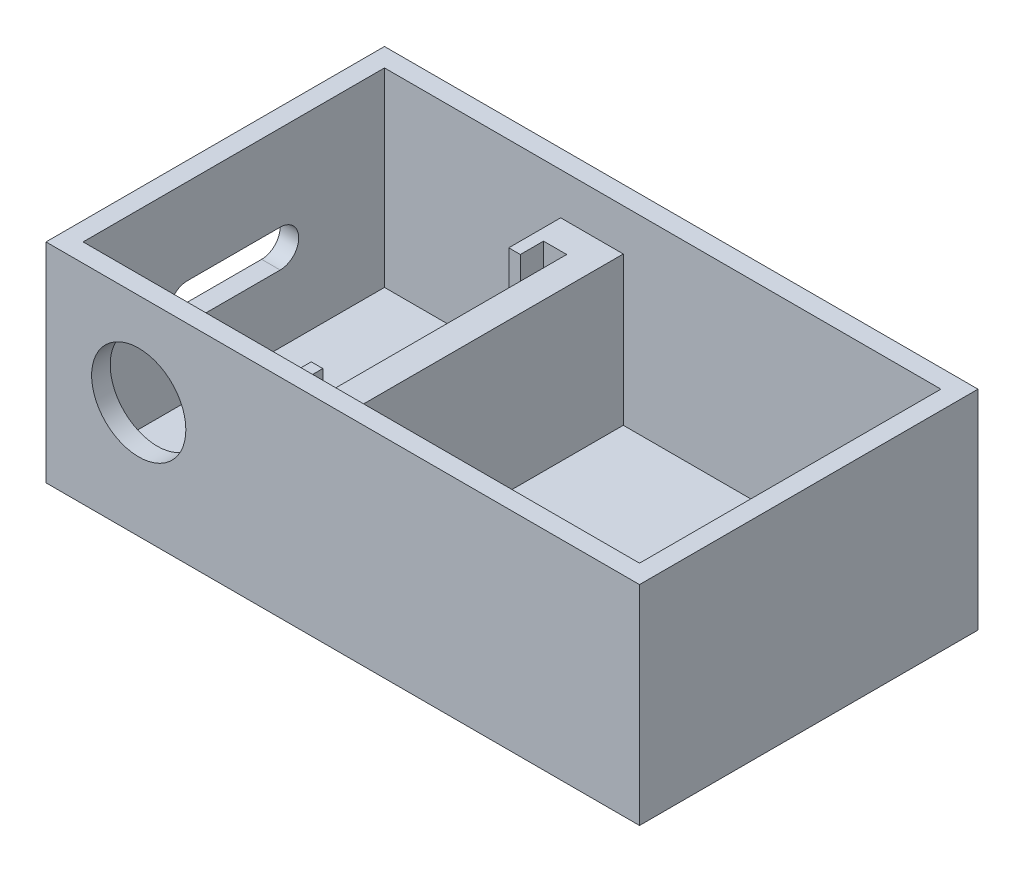
from build123d import *

# Parameters (mm, degrees)
SKETCH1_W           = 128
SKETCH1_H           = 73
SKETCH1_W_2         = 120
SKETCH1_H_2         = 65
BOSS_EXTRUDE1_DEPTH = 41
SKETCH1_3_W         = 128
SKETCH1_3_H         = 73
BOSS_EXTRUDE2_DEPTH = 4
SKETCH3_R           = 10.16
CUT_EXTRUDE1_DEPTH  = 4
SKETCH5_W           = 6
SKETCH5_H           = 65
BOSS_EXTRUDE3_DEPTH = 32
BOSS_EXTRUDE4_DEPTH = 32
CUT_EXTRUDE2_DEPTH  = 10


with BuildPart() as part:
    # Sketch1 → Boss-Extrude1 (new body)
    with BuildSketch(Plane(origin=(0, 0, 0), x_dir=(1, 0, 0), z_dir=(0, 1, 0))):
        Rectangle(SKETCH1_W, SKETCH1_H)
        Rectangle(SKETCH1_W_2, SKETCH1_H_2, mode=Mode.SUBTRACT)
    extrude(amount=BOSS_EXTRUDE1_DEPTH)

    # Sketch1_3 → Boss-Extrude2 (add)
    with BuildSketch(Plane(origin=(0, 0, 0), x_dir=(1, 0, 0), z_dir=(0, 1, 0))):
        Rectangle(SKETCH1_3_W, SKETCH1_3_H)
    extrude(amount=-BOSS_EXTRUDE2_DEPTH)

    # Sketch3 → Cut-Extrude1 (cut)
    with BuildSketch(Plane.XY.offset(36.5)):
        with Locations((-44, 21)):
            Circle(SKETCH3_R)
    extrude(amount=-CUT_EXTRUDE1_DEPTH, mode=Mode.SUBTRACT)

    # Sketch5 → Boss-Extrude3 (add)
    with BuildSketch(Plane(origin=(0, 0, 0), x_dir=(1, 0, 0), z_dir=(0, 1, 0))):
        with Locations((-11.5, 0)):
            Rectangle(SKETCH5_W, SKETCH5_H)
    extrude(amount=BOSS_EXTRUDE3_DEPTH)

    # Sketch8 → Boss-Extrude4 (add)
    with BuildSketch(Plane(origin=(0, 0, 0), x_dir=(1, 0, 0), z_dir=(0, 1, 0))):
        Polygon((-14.5, 32.5), (-22, 32.5), (-22, 21.3), (-19.5, 21.3), (-19.5, 26.3), (-14.5, 26.3), align=None)
        Polygon((-14.5, -26.3), (-14.5, -32.5), (-22, -32.5), (-22, -21.3), (-19.5, -21.3), (-19.5, -26.3), align=None)
    extrude(amount=BOSS_EXTRUDE4_DEPTH)

    # Sketch4 → Cut-Extrude2 (cut)
    with BuildSketch(Plane.ZY.offset(64)):
        with BuildLine():
            Line((10, 14.5), (-10, 14.5))
            ThreePointArc((-10, 14.5), (-14, 18.5), (-10, 22.5))
            Line((-10, 22.5), (10, 22.5))
            ThreePointArc((10, 22.5), (14, 18.5), (10, 14.5))
        make_face()
    extrude(amount=-CUT_EXTRUDE2_DEPTH, mode=Mode.SUBTRACT)


solid = part.part
